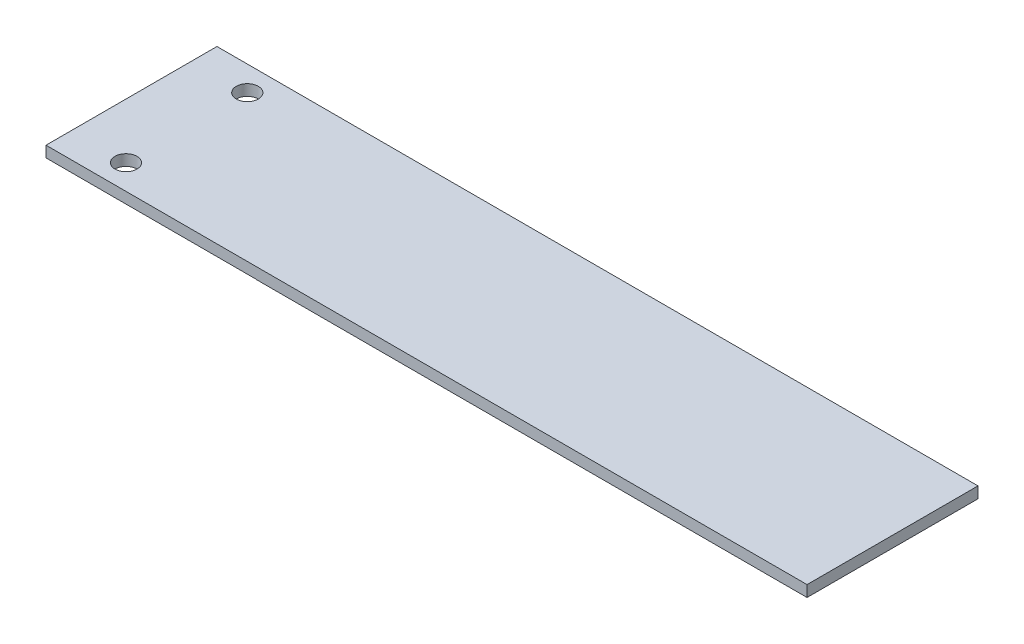
from build123d import *

# Parameters (mm, degrees)
SKETCH1_W                 = 19
SKETCH1_H                 = 15.5
BOSS_EXTRUDE1_DEPTH       = 1
F_1_0MM_DOWEL_HOLE1_D     = 2
F_1_0MM_DOWEL_HOLE1_DEPTH = 25
F_1_0MM_DOWEL_HOLE1_TIP   = 0.600860619
SKETCH4_W                 = 15.5
SKETCH4_H                 = 1.015904831
BOSS_EXTRUDE2_DEPTH       = 50


with BuildPart() as part:
    # Sketch1 → Boss-Extrude1 (new body)
    with BuildSketch(Plane(origin=(0, 0, 0), x_dir=(1, 0, 0), z_dir=(0, 1, 0))):
        with Locations((-2.301324503, -0.240066225)):
            Rectangle(SKETCH1_W, SKETCH1_H)
    extrude(amount=BOSS_EXTRUDE1_DEPTH)

    # Ø1.0mm Dowel Hole1
    with Locations(Plane(origin=(0, 1, 0), x_dir=(1, 0, 0), z_dir=(0, 1, 0))):
        with Locations((-6.801324503, 5.259933775), (-6.801324503, -5.740066225)):
            Hole(F_1_0MM_DOWEL_HOLE1_D / 2, depth=F_1_0MM_DOWEL_HOLE1_DEPTH)
            with Locations((0, 0, -(F_1_0MM_DOWEL_HOLE1_DEPTH + F_1_0MM_DOWEL_HOLE1_TIP / 2))):  # 118° drill point
                Cone(0, F_1_0MM_DOWEL_HOLE1_D / 2, F_1_0MM_DOWEL_HOLE1_TIP, mode=Mode.SUBTRACT)

    # Sketch4 → Boss-Extrude2 (add)
    with BuildSketch(Plane(origin=(7.198675497, 0, 0), x_dir=(0, 0, -1), z_dir=(1, 0, 0))):
        with Locations((-0.240066225, 0.492047585)):
            Rectangle(SKETCH4_W, SKETCH4_H)
    extrude(amount=BOSS_EXTRUDE2_DEPTH)


solid = part.part
